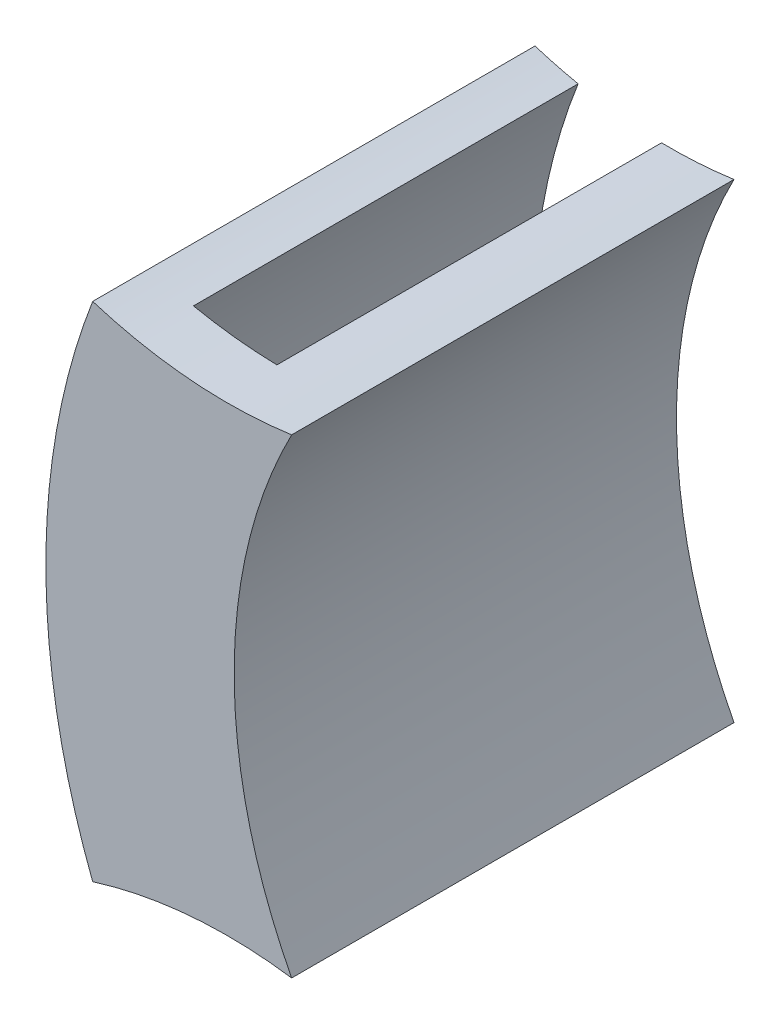
from build123d import *

# Parameters (mm, degrees)
BOSS_EXTRUDE1_DEPTH = 3
BOSS_EXTRUDE2_DEPTH = 20


with BuildPart() as part:
    # Sketch1 → Boss-Extrude1 (new body)
    with BuildSketch(Plane.XY):
        with BuildLine():
            ThreePointArc((28.476711912, -13.065389126), (26.043422294, 0), (28.476711912, 13.065389126))
            ThreePointArc((28.476711912, 13.065389126), (33.603633576, 12.069057908), (38.823996353, 12.229725621))
            ThreePointArc((38.823996353, 12.229725621), (35.833644105, 0), (38.823996353, -12.229725621))
            ThreePointArc((38.823996353, -12.229725621), (33.603633576, -12.069057908), (28.476711912, -13.065389126))
        make_face()
    extrude(amount=BOSS_EXTRUDE1_DEPTH)

    # Sketch2 → Boss-Extrude2 (add)
    with BuildSketch(Plane(origin=(0, 0, 0), x_dir=(-1, 0, 0), z_dir=(0, 0, -1))):
        with BuildLine():
            ThreePointArc((-30.718530844, -12.483407407), (-28.343422286, 0), (-30.718530844, 12.483407407))
            ThreePointArc((-30.718530844, 12.483407407), (-29.5904471, 12.746762635), (-28.476711912, 13.065389126))
            ThreePointArc((-28.476711912, 13.065389126), (-26.043422294, 0), (-28.476711912, -13.065389126))
            ThreePointArc((-28.476711912, -13.065389126), (-29.5904471, -12.746762635), (-30.718530844, -12.483407407))
        make_face()
        with BuildLine():
            ThreePointArc((-38.823996353, 12.229725621), (-35.833644105, 0), (-38.823996353, -12.229725621))
            ThreePointArc((-38.823996353, -12.229725621), (-36.94579852, -12.037595161), (-35.058238797, -11.996858122))
            ThreePointArc((-35.058238797, -11.996858122), (-32.536736444, 0), (-35.058238797, 11.996858122))
            ThreePointArc((-35.058238797, 11.996858122), (-36.94579852, 12.037595161), (-38.823996353, 12.229725621))
        make_face()
    extrude(amount=BOSS_EXTRUDE2_DEPTH)


solid = part.part
